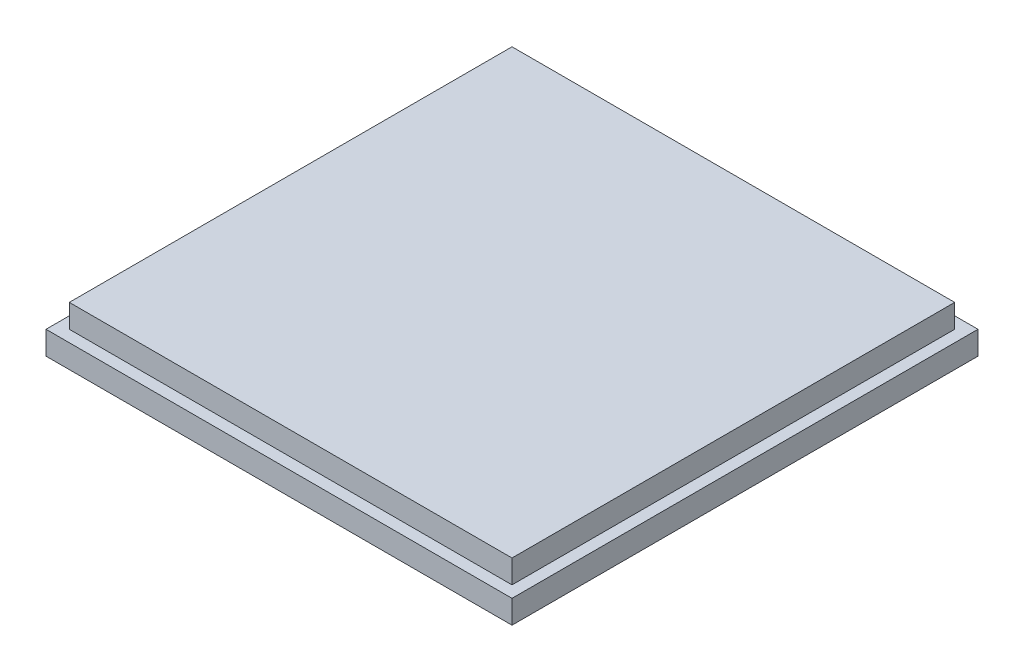
from build123d import *

# Parameters (mm, degrees)
SKETCH1_W           = 50.8
SKETCH1_H           = 50.8
BOSS_EXTRUDE1_DEPTH = 2.54
SKETCH2_W           = 48.26
SKETCH2_H           = 48.26
BOSS_EXTRUDE2_DEPTH = 2.54


with BuildPart() as part:
    # Sketch1 → Boss-Extrude1 (new body)
    with BuildSketch(Plane(origin=(0, 0, 0), x_dir=(1, 0, 0), z_dir=(0, 1, 0))):
        with Locations((25.4, 25.4)):
            Rectangle(SKETCH1_W, SKETCH1_H)
    extrude(amount=BOSS_EXTRUDE1_DEPTH)

    # Sketch2 → Boss-Extrude2 (add)
    with BuildSketch(Plane(origin=(0, 2.54, 0), x_dir=(1, 0, 0), z_dir=(0, 1, 0))):
        with Locations((25.4, 25.4)):
            Rectangle(SKETCH2_W, SKETCH2_H)
    extrude(amount=BOSS_EXTRUDE2_DEPTH)


solid = part.part
